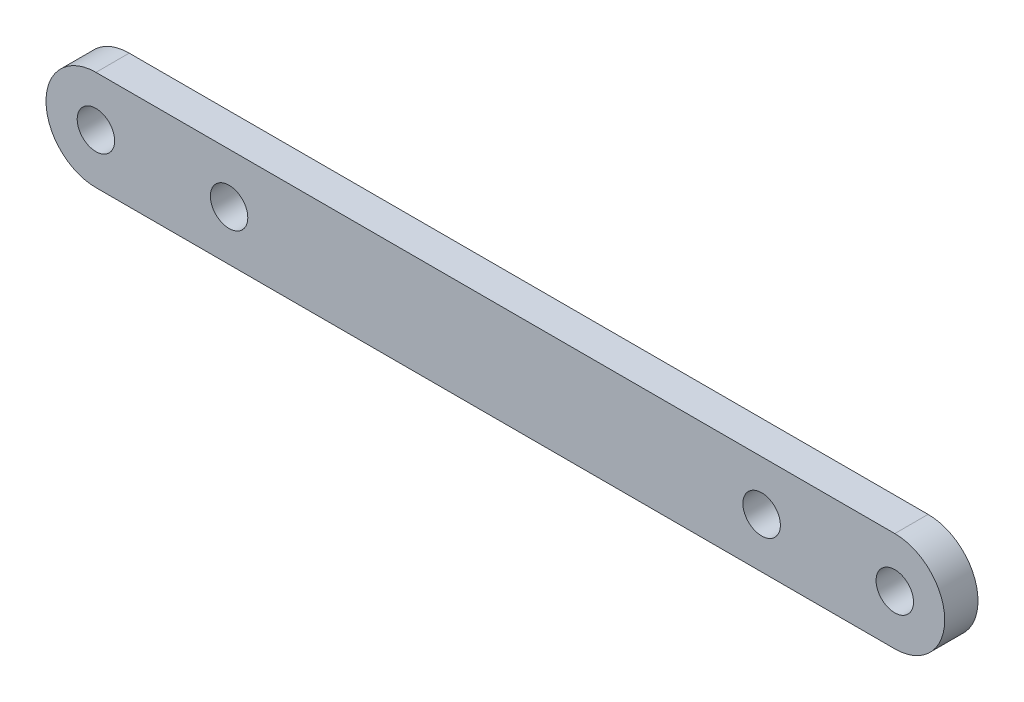
from build123d import *

# Parameters (mm, degrees)
BOSS_EXTRUDE1_DEPTH             = 3.175
F_9_64_0_14063_DIAMETER_HOLE1_D = 3.572002
F_9_64_0_14063_DIAMETER_HOLE2_D = 3.572002


with BuildPart() as part:
    # Sketch1 → Boss-Extrude1 (new body)
    with BuildSketch(Plane.XY):
        with BuildLine():
            Line((0, -4.7625), (-76.2, -4.7625))
            ThreePointArc((-76.2, -4.7625), (-80.9625, 0), (-76.2, 4.7625))
            Line((-76.2, 4.7625), (0, 4.7625))
            ThreePointArc((0, 4.7625), (4.7625, 0), (0, -4.7625))
        make_face()
    extrude(amount=BOSS_EXTRUDE1_DEPTH)

    # 9/64 (0.14063) Diameter Hole1 (through all)
    with Locations(Plane.XY.offset(3.175)):
        with Locations((0, 0), (-76.2, 0)):
            Hole(F_9_64_0_14063_DIAMETER_HOLE1_D / 2)

    # 9/64 (0.14063) Diameter Hole2 (through all)
    with Locations(Plane.XY.offset(3.175)):
        with Locations((-12.7, 0), (-63.5, 0)):
            Hole(F_9_64_0_14063_DIAMETER_HOLE2_D / 2)


solid = part.part
